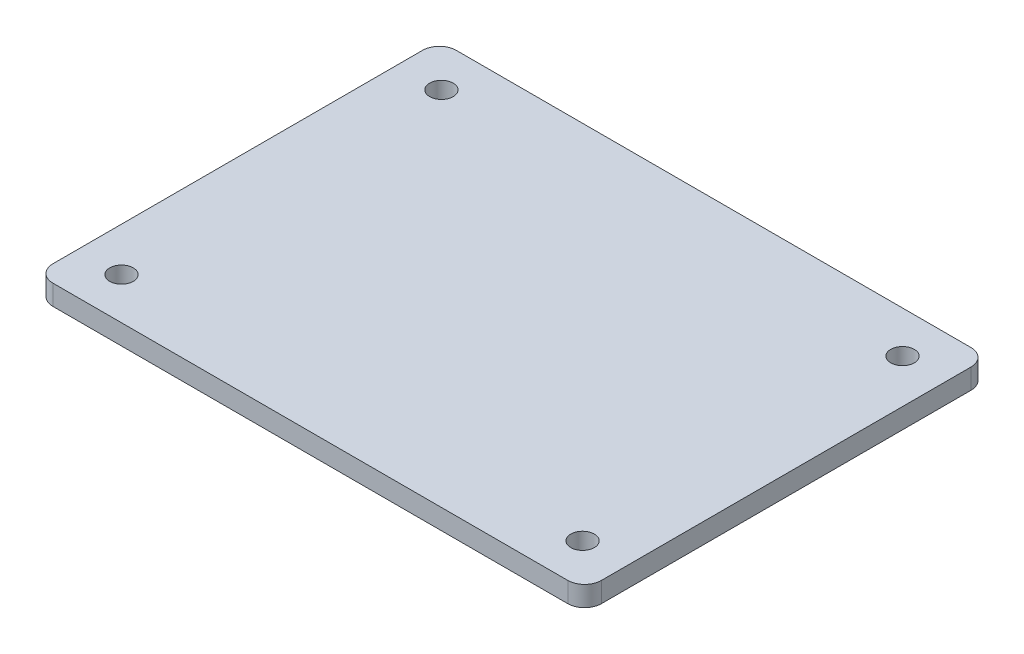
from build123d import *

# Parameters (mm, degrees)
CROQUIS1_R              = 1.75
SALIENTE_EXTRUIR1_DEPTH = 3


with BuildPart() as part:
    # Croquis1 → Saliente-Extruir1 (new body)
    with BuildSketch(Plane(origin=(0, 0, 0), x_dir=(1, 0, 0), z_dir=(0, 1, 0))):
        with BuildLine():
            Line((-38.3, -30), (38.3, -30))
            ThreePointArc((38.3, -30), (40.067766953, -29.267766953), (40.8, -27.5))
            Line((40.8, -27.5), (40.8, 27.5))
            ThreePointArc((40.8, 27.5), (40.067766953, 29.267766953), (38.3, 30))
            Line((38.3, 30), (-38.3, 30))
            ThreePointArc((-38.3, 30), (-40.067766953, 29.267766953), (-40.8, 27.5))
            Line((-40.8, 27.5), (-40.8, -27.5))
            ThreePointArc((-40.8, -27.5), (-40.067766953, -29.267766953), (-38.3, -30))
        make_face()
        with Locations((-34.3, 23.8)):
            Circle(CROQUIS1_R, mode=Mode.SUBTRACT)
        with Locations((-34.3, -23.8)):
            Circle(CROQUIS1_R, mode=Mode.SUBTRACT)
        with Locations((34.3, -23.8)):
            Circle(CROQUIS1_R, mode=Mode.SUBTRACT)
        with Locations((34.3, 23.8)):
            Circle(CROQUIS1_R, mode=Mode.SUBTRACT)
    extrude(amount=SALIENTE_EXTRUIR1_DEPTH)


solid = part.part
